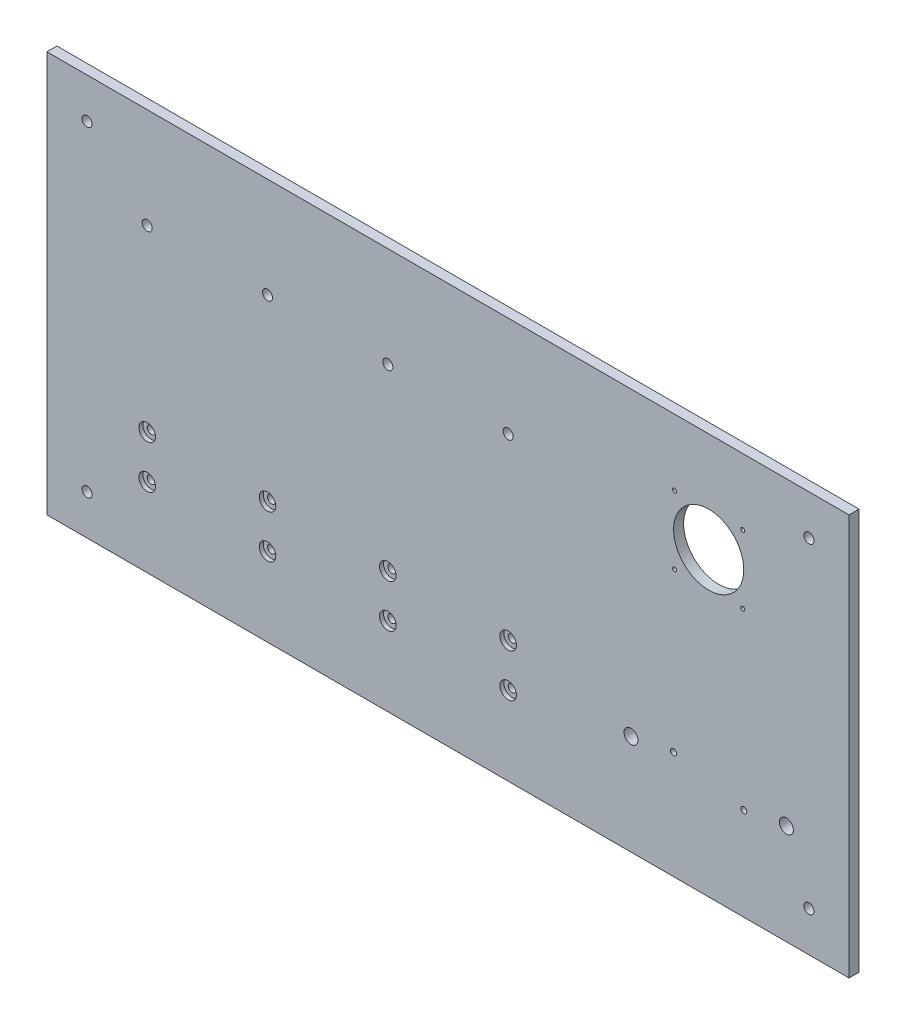
from build123d import *

# Parameters (mm, degrees)
SKETCH_1_W          = 800
SKETCH_1_H          = 400
SKETCH_1_R          = 35
SKETCH_1_R_2        = 2
SKETCH_1_R_3        = 5
SKETCH_1_R_4        = 4
SKETCH_1_R_5        = 7
SKETCH_1_R_6        = 3
EXTRUDE_1_DEPTH     = 10
SKETCH_2_R          = 8.25
CUT_EXTRUDE_1_DEPTH = 4


with BuildPart() as part:
    # Эскиз1 → Бобышка-Вытянуть1 (new body)
    with BuildSketch(Plane.XY):
        with Locations((400, 200)):
            Rectangle(SKETCH_1_W, SKETCH_1_H)
        with Locations((660, 300)):
            Circle(SKETCH_1_R, mode=Mode.SUBTRACT)
        with Locations((626, 334)):
            Circle(SKETCH_1_R_2, mode=Mode.SUBTRACT)
        with Locations((694, 334)):
            Circle(SKETCH_1_R_2, mode=Mode.SUBTRACT)
        with Locations((694, 266)):
            Circle(SKETCH_1_R_2, mode=Mode.SUBTRACT)
        with Locations((626, 266)):
            Circle(SKETCH_1_R_2, mode=Mode.SUBTRACT)
        with Locations((100, 300)):
            Circle(SKETCH_1_R_3, mode=Mode.SUBTRACT)
        with Locations((220, 300)):
            Circle(SKETCH_1_R_3, mode=Mode.SUBTRACT)
        with Locations((340, 300)):
            Circle(SKETCH_1_R_3, mode=Mode.SUBTRACT)
        with Locations((460, 300)):
            Circle(SKETCH_1_R_3, mode=Mode.SUBTRACT)
        with Locations((100, 121.5)):
            Circle(SKETCH_1_R_4, mode=Mode.SUBTRACT)
        with Locations((220, 121.5)):
            Circle(SKETCH_1_R_4, mode=Mode.SUBTRACT)
        with Locations((340, 121.5)):
            Circle(SKETCH_1_R_4, mode=Mode.SUBTRACT)
        with Locations((460, 121.5)):
            Circle(SKETCH_1_R_4, mode=Mode.SUBTRACT)
        with Locations((460, 78.5)):
            Circle(SKETCH_1_R_4, mode=Mode.SUBTRACT)
        with Locations((340, 78.5)):
            Circle(SKETCH_1_R_4, mode=Mode.SUBTRACT)
        with Locations((220, 78.5)):
            Circle(SKETCH_1_R_4, mode=Mode.SUBTRACT)
        with Locations((100, 78.5)):
            Circle(SKETCH_1_R_4, mode=Mode.SUBTRACT)
        with Locations((582.5, 100)):
            Circle(SKETCH_1_R_5, mode=Mode.SUBTRACT)
        with Locations((737.5, 100)):
            Circle(SKETCH_1_R_5, mode=Mode.SUBTRACT)
        with Locations((625, 107.5)):
            Circle(SKETCH_1_R_6, mode=Mode.SUBTRACT)
        with Locations((695, 92.5)):
            Circle(SKETCH_1_R_6, mode=Mode.SUBTRACT)
        with Locations((40, 360)):
            Circle(SKETCH_1_R_3, mode=Mode.SUBTRACT)
        with Locations((760, 360)):
            Circle(SKETCH_1_R_3, mode=Mode.SUBTRACT)
        with Locations((760, 40)):
            Circle(SKETCH_1_R_3, mode=Mode.SUBTRACT)
        with Locations((40, 40)):
            Circle(SKETCH_1_R_3, mode=Mode.SUBTRACT)
    extrude(amount=EXTRUDE_1_DEPTH)

    # Эскиз2 → Вырез-Вытянуть1 (cut)
    with BuildSketch(Plane.XY.offset(10)):
        with Locations((100, 121.5)):
            Circle(SKETCH_2_R)
        with Locations((100, 78.5)):
            Circle(SKETCH_2_R)
        with Locations((220, 121.5)):
            Circle(SKETCH_2_R)
        with Locations((220, 78.5)):
            Circle(SKETCH_2_R)
        with Locations((340, 121.5)):
            Circle(SKETCH_2_R)
        with Locations((460, 121.5)):
            Circle(SKETCH_2_R)
        with Locations((460, 78.5)):
            Circle(SKETCH_2_R)
        with Locations((340, 78.5)):
            Circle(SKETCH_2_R)
    extrude(amount=-CUT_EXTRUDE_1_DEPTH, mode=Mode.SUBTRACT)


solid = part.part
